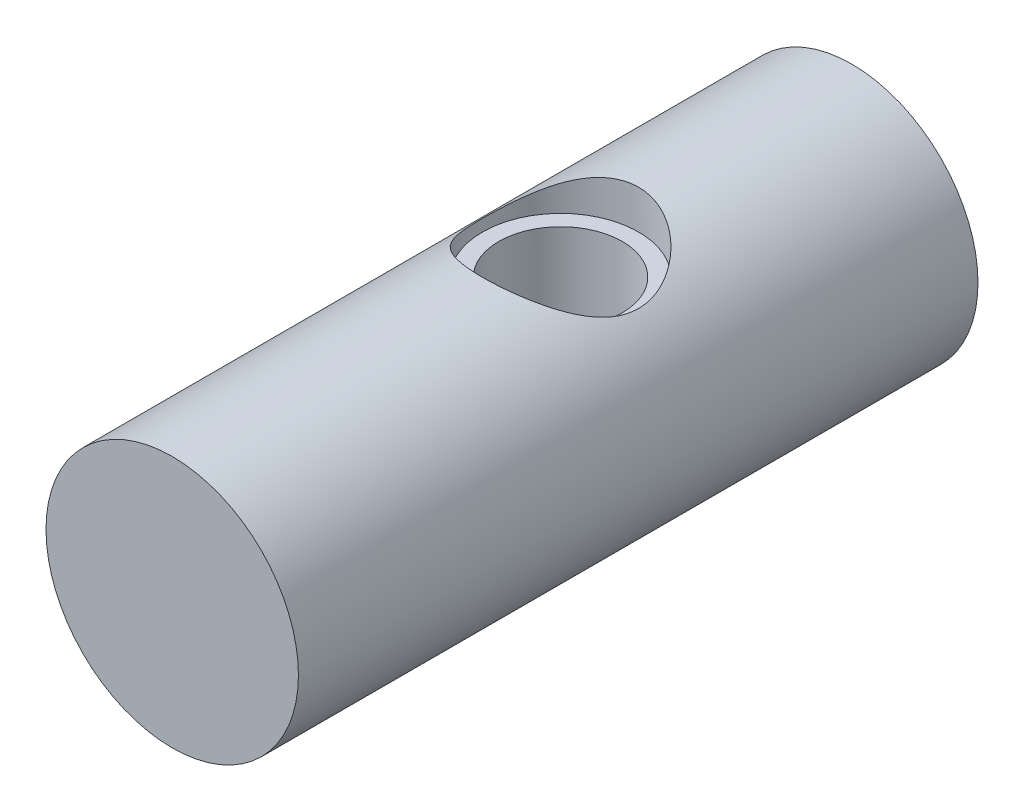
from build123d import *

# Parameters (mm, degrees)
SKETCH1_R                      = 4.1275
BOSS_EXTRUDE1_DEPTH            = 22.225
F_7_0_201_DIAMETER_HOLE1_D     = 5.1054
F_7_0_201_DIAMETER_HOLE1_DEPTH = 1.27
F_10_32_TAPPED_HOLE1_D         = 4.0386


with BuildPart() as part:
    # Sketch1 → Boss-Extrude1 (new body)
    with BuildSketch(Plane.XY):
        Circle(SKETCH1_R)
    extrude(amount=BOSS_EXTRUDE1_DEPTH)

    # #7 (0.201) Diameter Hole1
    with Locations(Plane(origin=(0, 4.1275, 9.525), x_dir=(1, 0, 0), z_dir=(0, 1, 0))):
        with Locations((0, 0)):
            Hole(F_7_0_201_DIAMETER_HOLE1_D / 2, depth=F_7_0_201_DIAMETER_HOLE1_DEPTH)

    # #10-32 Tapped Hole1 (through all)
    with Locations(Plane(origin=(0, 4.1275, 9.525), x_dir=(1, 0, 0), z_dir=(0, 1, 0))):
        with Locations((0, 0)):
            Hole(F_10_32_TAPPED_HOLE1_D / 2)


solid = part.part
